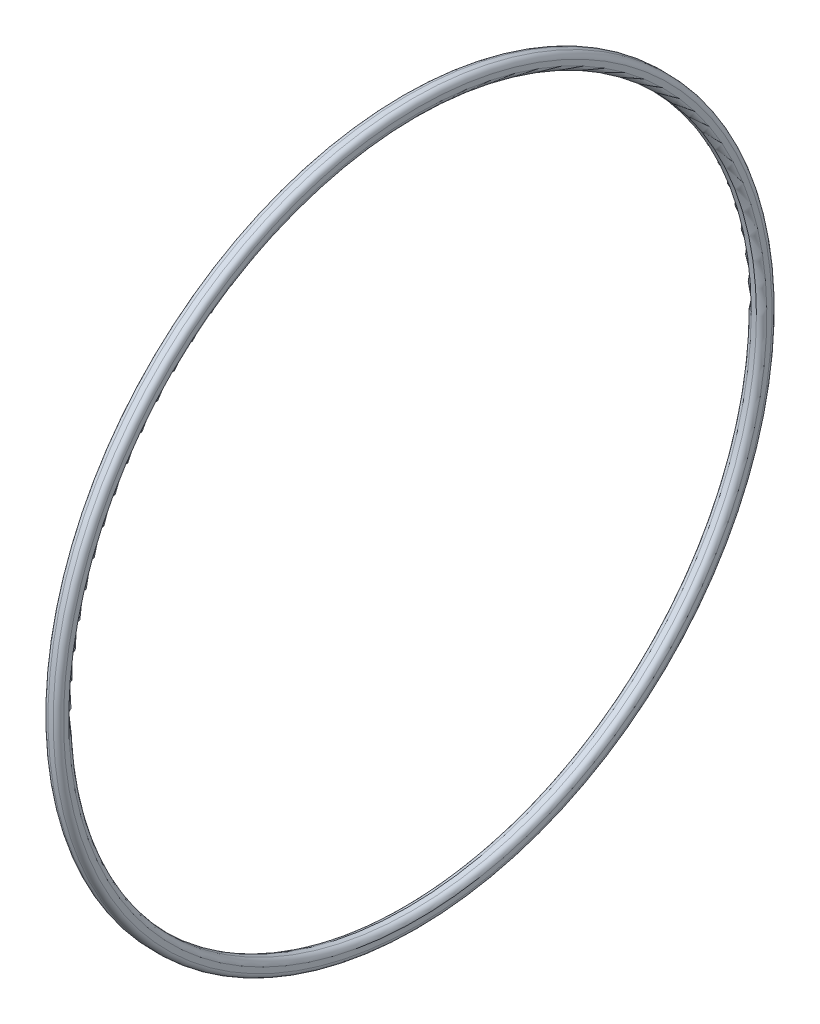
from build123d import *


with BuildPart() as part:
    # Schizzo1 → Rivoluzione1 (revolve)
    with BuildSketch(Plane.XY):
        with BuildLine():
            Line((-0.499798977, -1.5), (0.499798977, -1.5))
            ThreePointArc((0.499798977, -1.5), (1.206905758, -1.207106781), (1.499798977, -0.5))
            Line((1.499798977, -0.5), (1.499798977, 0.5))
            ThreePointArc((1.499798977, 0.5), (1.206905758, 1.207106781), (0.499798977, 1.5))
            Line((0.499798977, 1.5), (-0.499798977, 1.5))
            ThreePointArc((-0.499798977, 1.5), (-1.206905758, 1.207106781), (-1.499798977, 0.5))
            Line((-1.499798977, 0.5), (-1.499798977, -0.5))
            ThreePointArc((-1.499798977, -0.5), (-1.206905758, -1.207106781), (-0.499798977, -1.5))
        make_face()
    revolve(axis=Axis((0, -67.75, 0), (-1, 0, 0)))


solid = part.part
